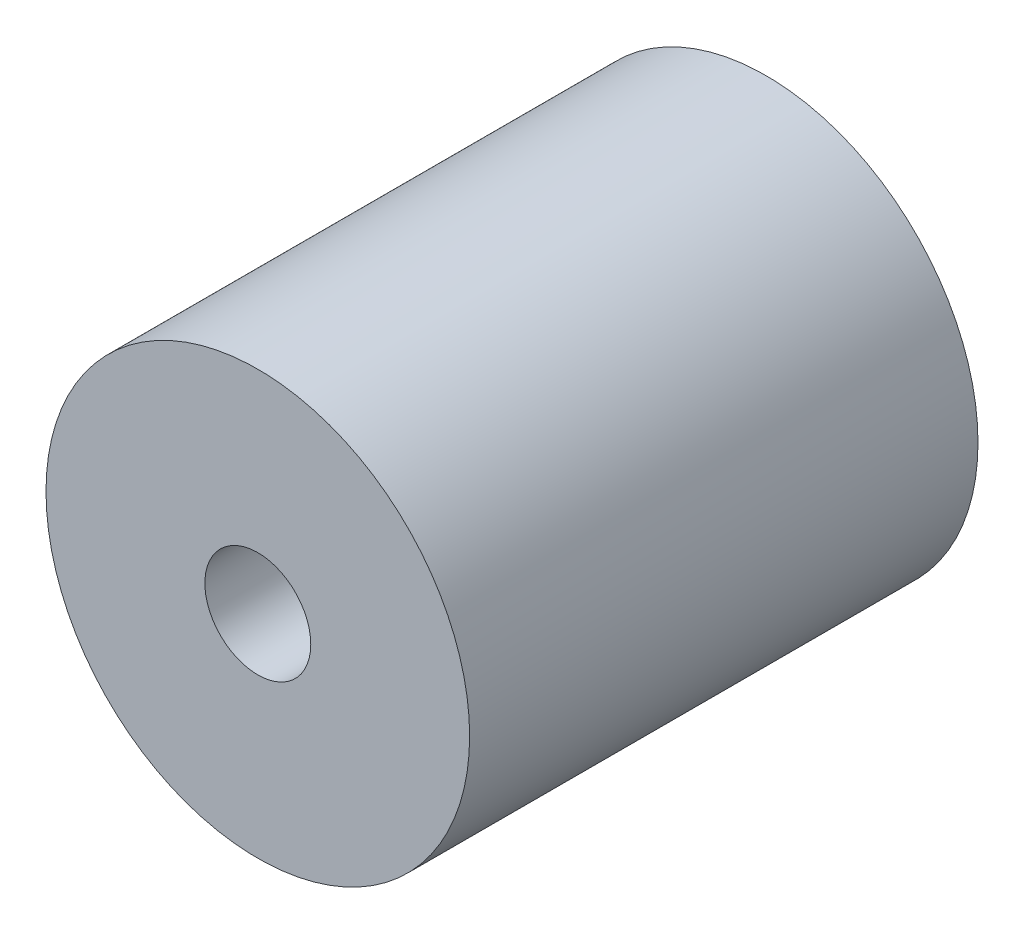
from build123d import *

# Parameters (mm, degrees)
SKETCH_1_R          = 10
EXTRUDE_1_DEPTH     = 24
SKETCH_2_R          = 2.5
CUT_EXTRUDE_1_DEPTH = 12
SKETCH_3_R          = 4
CUT_EXTRUDE_2_DEPTH = 12


with BuildPart() as part:
    # 草图1 → 凸台-拉伸1 (new body)
    with BuildSketch(Plane.XY):
        Circle(SKETCH_1_R)
    extrude(amount=EXTRUDE_1_DEPTH)

    # 草图2 → 切除-拉伸1 (cut)
    with BuildSketch(Plane.XY.offset(24)):
        Circle(SKETCH_2_R)
    extrude(amount=-CUT_EXTRUDE_1_DEPTH, mode=Mode.SUBTRACT)

    # 草图3 → 切除-拉伸2 (cut)
    with BuildSketch(Plane(origin=(0, 0, 0), x_dir=(-1, 0, 0), z_dir=(0, 0, -1))):
        Circle(SKETCH_3_R)
    extrude(amount=-CUT_EXTRUDE_2_DEPTH, mode=Mode.SUBTRACT)


solid = part.part
